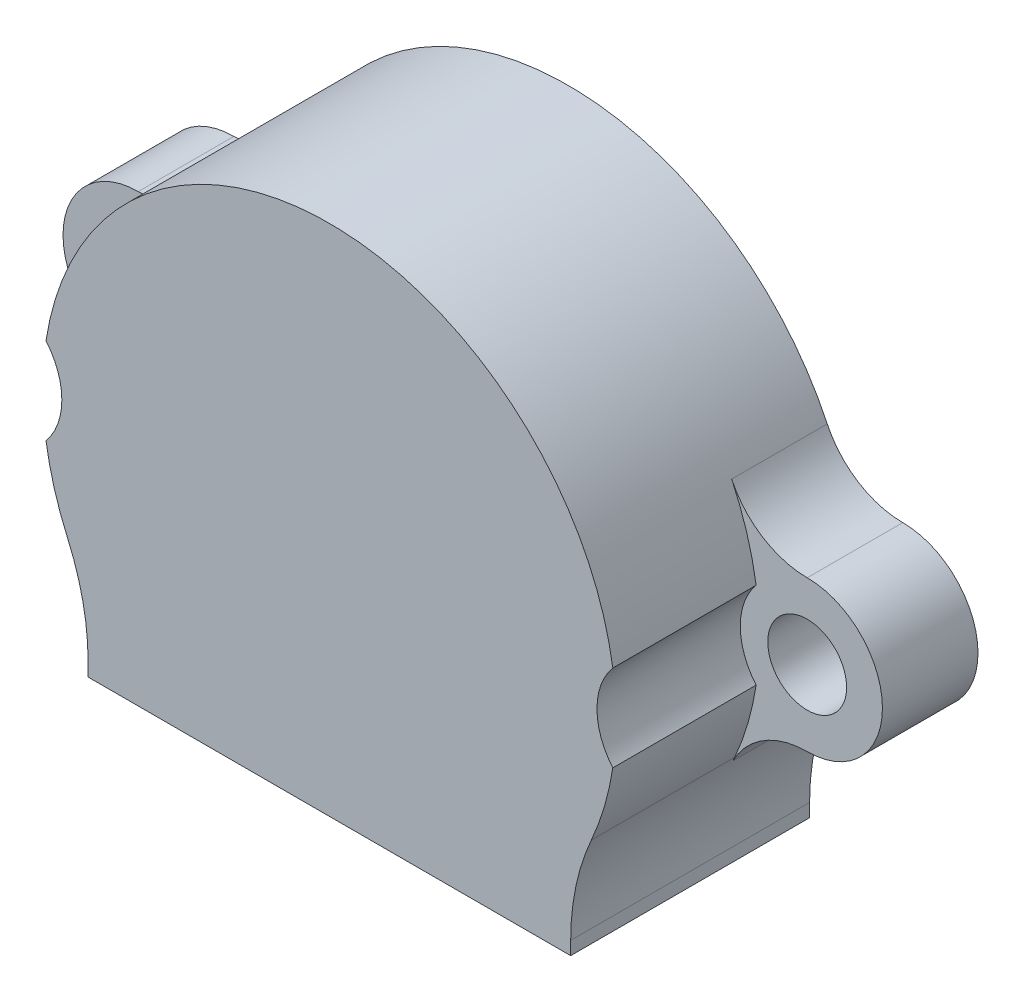
from build123d import *

# Parameters (mm, degrees)
BOSS_EXTRUDE1_DEPTH = 10
BOSS_EXTRUDE2_DEPTH = 0.8
FILLET1_R           = 10
SKETCH3_R           = 1.65
BOSS_EXTRUDE4_DEPTH = 4
SKETCH4_R           = 2.8
CUT_EXTRUDE1_DEPTH  = 7


with BuildPart() as part:
    # Sketch1 → Boss-Extrude1 (new body)
    with BuildSketch(Plane.XY):
        with BuildLine():
            Line((-7.6, -4.13067791), (-7.6, -9.5))
            Line((-7.6, -9.5), (-10.1, -9.5))
            Line((-10.1, -9.5), (-10.1, -6.479969136))
            ThreePointArc((-10.1, -6.479969136), (0, 12), (10.1, -6.479969136))
            Line((10.1, -6.479969136), (10.1, -9.5))
            Line((10.1, -9.5), (7.6, -9.5))
            Line((7.6, -9.5), (7.6, -4.13067791))
            ThreePointArc((7.6, -4.13067791), (0, 8.65), (-7.6, -4.13067791))
        make_face()
    extrude(amount=BOSS_EXTRUDE1_DEPTH)

    # Sketch2 → Boss-Extrude2 (add)
    with BuildSketch(Plane.XY.offset(10)):
        with BuildLine():
            Line((7.6, -4.13067791), (7.6, -9.5))
            Line((7.6, -9.5), (-7.6, -9.5))
            Line((-7.6, -9.5), (-7.6, -4.13067791))
            ThreePointArc((-7.6, -4.13067791), (0, 8.65), (7.6, -4.13067791))
        make_face()
    extrude(amount=-BOSS_EXTRUDE2_DEPTH)

    # Fillet1
    fillet1_edges = [part.edges().sort_by_distance(p)[0] for p in [
        (10.1, -6.479969136, 5),
        (-10.1, -6.479969136, 5),
    ]]
    fillet(fillet1_edges, radius=FILLET1_R)

    # Sketch3 → Boss-Extrude4 (add)
    with BuildSketch(Plane(origin=(0, 0, 0), x_dir=(-1, 0, 0), z_dir=(0, 0, -1))):
        with BuildLine():
            ThreePointArc((14, 3.15), (17.15, 0), (14, -3.15))
            ThreePointArc((14, -3.15), (12.130662272, -3.6913019), (10.839796225, -5.147700243))
            ThreePointArc((10.839796225, -5.147700243), (12, 0), (10.839796225, 5.147700243))
            ThreePointArc((10.839796225, 5.147700243), (12.130662272, 3.6913019), (14, 3.15))
        make_face()
        with Locations((14, 0)):
            Circle(SKETCH3_R, mode=Mode.SUBTRACT)
        with BuildLine():
            ThreePointArc((-10.839796225, 5.147700243), (-12, 0), (-10.839796225, -5.147700243))
            ThreePointArc((-10.839796225, -5.147700243), (-12.130662272, -3.6913019), (-14, -3.15))
            ThreePointArc((-14, -3.15), (-17.15, 0), (-14, 3.15))
            ThreePointArc((-14, 3.15), (-12.130662272, 3.6913019), (-10.839796225, 5.147700243))
        make_face()
        with Locations((-14, 0)):
            Circle(SKETCH3_R, mode=Mode.SUBTRACT)
    extrude(amount=-BOSS_EXTRUDE4_DEPTH)

    # Sketch4 → Cut-Extrude1 (cut, through all)
    with BuildSketch(Plane.XY.offset(4)):
        with Locations((-14, 0)):
            Circle(SKETCH4_R)
        with Locations((14, 0)):
            Circle(SKETCH4_R)
    extrude(amount=CUT_EXTRUDE1_DEPTH, mode=Mode.SUBTRACT)


solid = part.part
